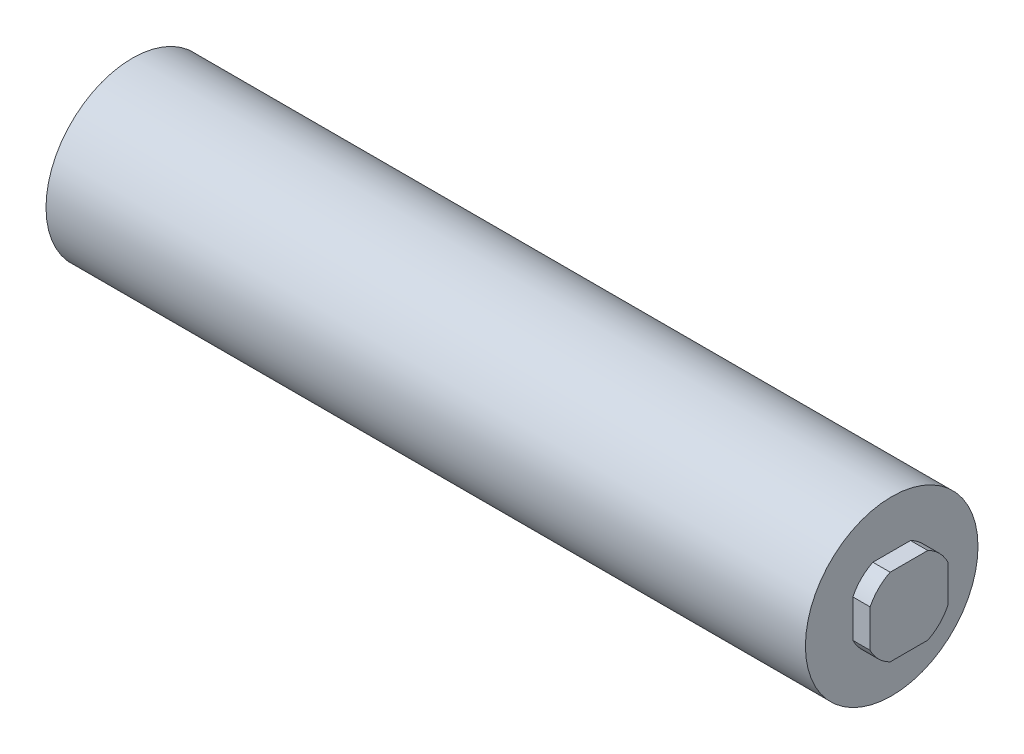
from build123d import *

# Parameters (mm, degrees)
SKETCH1_R           = 5
BOSS_EXTRUDE1_DEPTH = 44
SKETCH2_R           = 2.5
BOSS_EXTRUDE2_DEPTH = 1
SKETCH3_OUTSIDE_W   = 21.434
SKETCH3_OUTSIDE_H   = 21.434
SKETCH3_OUTSIDE_W_2 = 4.5
SKETCH3_OUTSIDE_H_2 = 4.5
CUT_EXTRUDE1_DEPTH  = 1


with BuildPart() as part:
    # Sketch1 → Boss-Extrude1 (new body)
    with BuildSketch(Plane(origin=(0, 0, 0), x_dir=(0, 0, -1), z_dir=(1, 0, 0))):
        Circle(SKETCH1_R)
    extrude(amount=BOSS_EXTRUDE1_DEPTH)

    # Sketch2 → Boss-Extrude2 (add)
    with BuildSketch(Plane(origin=(44, 0, 0), x_dir=(0, 0, -1), z_dir=(1, 0, 0))):
        Circle(SKETCH2_R)
    extrude(amount=BOSS_EXTRUDE2_DEPTH)

    # Sketch3 outside → Cut-Extrude1 (cut)
    with BuildSketch(Plane(origin=(45, 0, 0), x_dir=(0, 0, -1), z_dir=(1, 0, 0))):
        Rectangle(SKETCH3_OUTSIDE_W, SKETCH3_OUTSIDE_H)
        Rectangle(SKETCH3_OUTSIDE_W_2, SKETCH3_OUTSIDE_H_2, mode=Mode.SUBTRACT)
    extrude(amount=-CUT_EXTRUDE1_DEPTH, mode=Mode.SUBTRACT)


solid = part.part
